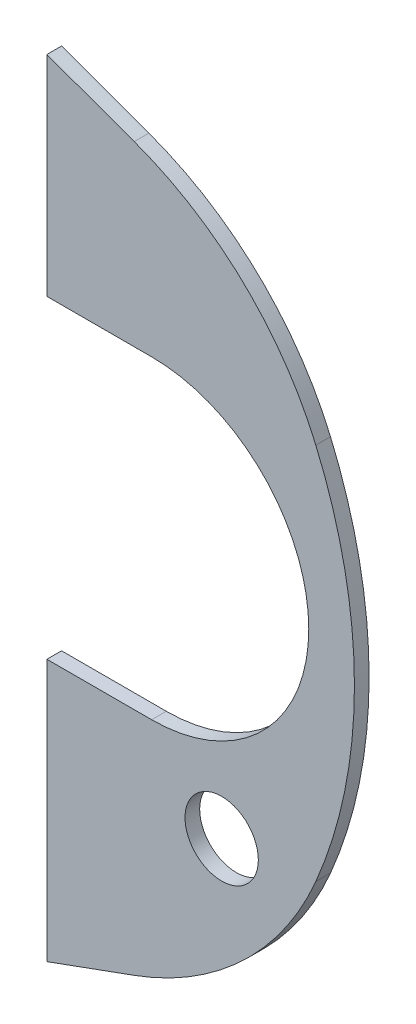
from build123d import *

# Parameters (mm, degrees)
BOSS_EXTRUDE1_DEPTH = 0.7
SKETCH2_R           = 1.75
CUT_EXTRUDE1_DEPTH  = 10
FILLET1_R           = 15


with BuildPart() as part:
    # Sketch1 → Boss-Extrude1 (new body)
    with BuildSketch(Plane.XY):
        with BuildLine():
            Line((0, 0), (5, 0))
            ThreePointArc((5, 0), (14.679433195, 18.75), (5, 37.5))
            Line((5, 37.5), (0, 37.5))
            Line((0, 37.5), (0, 27.5))
            Line((0, 27.5), (5, 27.5))
            ThreePointArc((5, 27.5), (12.5, 20), (5, 12.5))
            Line((5, 12.5), (0, 12.5))
            Line((0, 12.5), (0, 0))
        make_face()
    extrude(amount=BOSS_EXTRUDE1_DEPTH)

    # Sketch2 → Cut-Extrude1 (cut)
    with BuildSketch(Plane.XY.offset(0.7)):
        with Locations((8.342000555, 9.25262746)):
            Circle(SKETCH2_R)
        Polygon((0, 37.5), (13.374942175, 32.631919163), (10.545086025, 37.5), align=None)
        Polygon((0, 0), (14.645857922, 5.330656339), (11.681927556, 0), align=None)
    extrude(amount=-CUT_EXTRUDE1_DEPTH, mode=Mode.SUBTRACT)

    # Fillet1
    fillet1_edges = [part.edges().sort_by_distance(p)[0] for p in [
        (8.542627357, 34.39073792, 0.35),
        (8.542627357, 3.10926208, 0.35),
    ]]
    fillet(fillet1_edges, radius=FILLET1_R)


solid = part.part
